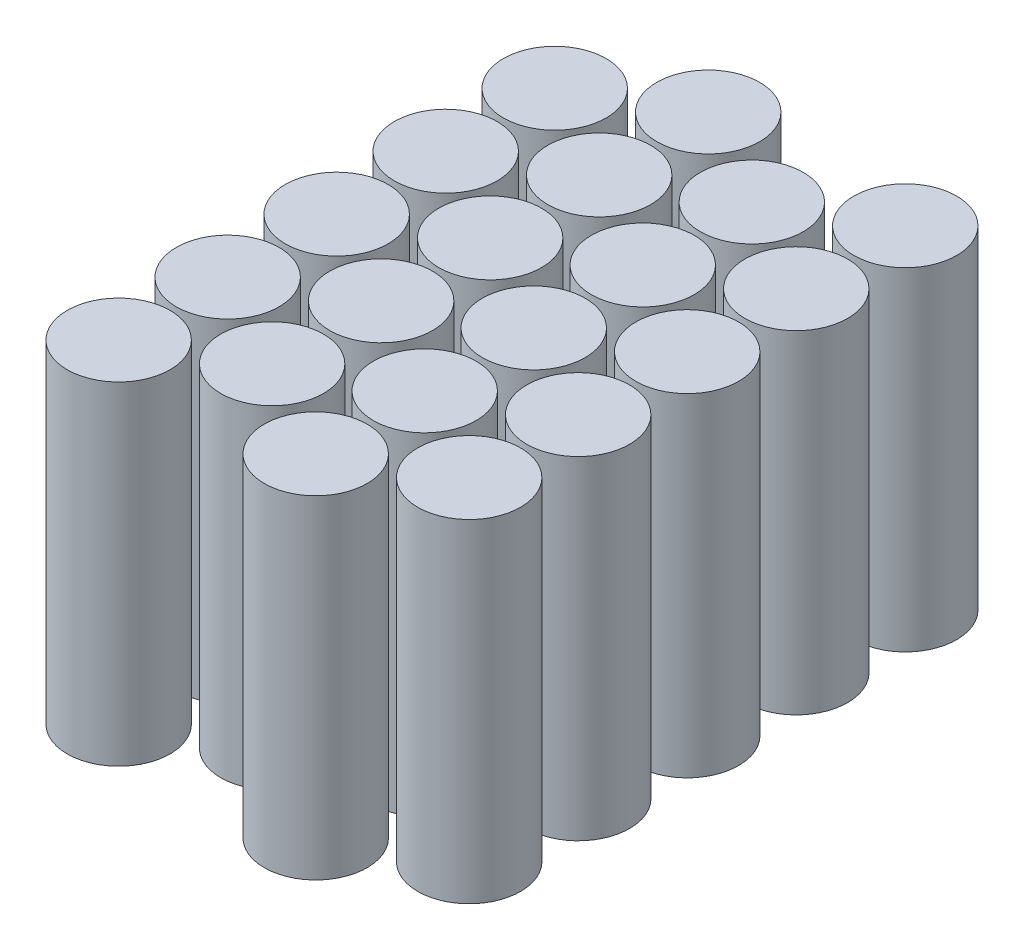
from build123d import *

# Parameters (mm, degrees)
SKETCH1_R                    = 10.85
MOLICELLL_21700_4S5P_DEPTH   = 35.1
MOLICELLL_21700_4S5P_2_DEPTH = 35.1
LPATTERN1_COUNT              = 5
LPATTERN1_PITCH              = 23
LPATTERN2_COUNT              = 2
LPATTERN2_PITCH              = 41.57


with BuildPart() as part:
    # Sketch1 → Molicelll 21700 - 4s5p (new body, symmetric)
    with BuildSketch(Plane(origin=(0, 0, 0), x_dir=(1, 0, 0), z_dir=(0, 1, 0))):
        Circle(SKETCH1_R)
    extrude(amount=MOLICELLL_21700_4S5P_DEPTH, both=True)


with BuildPart() as body_2:
    # Sketch1 → Molicelll 21700 - 4s5p 2 (new body, symmetric)
    with BuildSketch(Plane(origin=(0, 0, 0), x_dir=(1, 0, 0), z_dir=(0, 1, 0))):
        with Locations((20.52480207, 11.85)):
            Circle(SKETCH1_R)
    extrude(amount=MOLICELLL_21700_4S5P_2_DEPTH, both=True)


with BuildPart() as lpattern1_1:
    # LPattern1: pattern copy
    add(part.part.moved(Location(Vector(0, 0, 1) * (1 * LPATTERN1_PITCH))))


with BuildPart() as lpattern1_2:
    # LPattern1: pattern copy
    add(part.part.moved(Location(Vector(0, 0, 1) * (2 * LPATTERN1_PITCH))))


with BuildPart() as lpattern1_3:
    # LPattern1: pattern copy
    add(part.part.moved(Location(Vector(0, 0, 1) * (3 * LPATTERN1_PITCH))))


with BuildPart() as lpattern1_4:
    # LPattern1: pattern copy
    add(part.part.moved(Location(Vector(0, 0, 1) * (4 * LPATTERN1_PITCH))))


with BuildPart() as lpattern1_5:
    # LPattern1: pattern copy
    add(body_2.part.moved(Location(Vector(0, 0, 1) * (1 * LPATTERN1_PITCH))))


with BuildPart() as lpattern1_6:
    # LPattern1: pattern copy
    add(body_2.part.moved(Location(Vector(0, 0, 1) * (2 * LPATTERN1_PITCH))))


with BuildPart() as lpattern1_7:
    # LPattern1: pattern copy
    add(body_2.part.moved(Location(Vector(0, 0, 1) * (3 * LPATTERN1_PITCH))))


with BuildPart() as lpattern1_8:
    # LPattern1: pattern copy
    add(body_2.part.moved(Location(Vector(0, 0, 1) * (4 * LPATTERN1_PITCH))))


with BuildPart() as lpattern2_1:
    # LPattern2: pattern copy
    add(part.part.moved(Location(Vector(1, 0, 0) * (1 * LPATTERN2_PITCH))))


with BuildPart() as lpattern2_2:
    # LPattern2: pattern copy
    add(body_2.part.moved(Location(Vector(1, 0, 0) * (1 * LPATTERN2_PITCH))))


with BuildPart() as lpattern2_3:
    # LPattern2: pattern copy
    add(lpattern1_1.part.moved(Location(Vector(1, 0, 0) * (1 * LPATTERN2_PITCH))))


with BuildPart() as lpattern2_4:
    # LPattern2: pattern copy
    add(lpattern1_5.part.moved(Location(Vector(1, 0, 0) * (1 * LPATTERN2_PITCH))))


with BuildPart() as lpattern2_5:
    # LPattern2: pattern copy
    add(lpattern1_2.part.moved(Location(Vector(1, 0, 0) * (1 * LPATTERN2_PITCH))))


with BuildPart() as lpattern2_6:
    # LPattern2: pattern copy
    add(lpattern1_6.part.moved(Location(Vector(1, 0, 0) * (1 * LPATTERN2_PITCH))))


with BuildPart() as lpattern2_7:
    # LPattern2: pattern copy
    add(lpattern1_3.part.moved(Location(Vector(1, 0, 0) * (1 * LPATTERN2_PITCH))))


with BuildPart() as lpattern2_8:
    # LPattern2: pattern copy
    add(lpattern1_7.part.moved(Location(Vector(1, 0, 0) * (1 * LPATTERN2_PITCH))))


with BuildPart() as lpattern2_9:
    # LPattern2: pattern copy
    add(lpattern1_4.part.moved(Location(Vector(1, 0, 0) * (1 * LPATTERN2_PITCH))))


with BuildPart() as lpattern2_10:
    # LPattern2: pattern copy
    add(lpattern1_8.part.moved(Location(Vector(1, 0, 0) * (1 * LPATTERN2_PITCH))))


solid = Compound([part.part, body_2.part, lpattern1_1.part, lpattern1_2.part, lpattern1_3.part, lpattern1_4.part, lpattern1_5.part, lpattern1_6.part, lpattern1_7.part, lpattern1_8.part, lpattern2_1.part, lpattern2_2.part, lpattern2_3.part, lpattern2_4.part, lpattern2_5.part, lpattern2_6.part, lpattern2_7.part, lpattern2_8.part, lpattern2_9.part, lpattern2_10.part])
